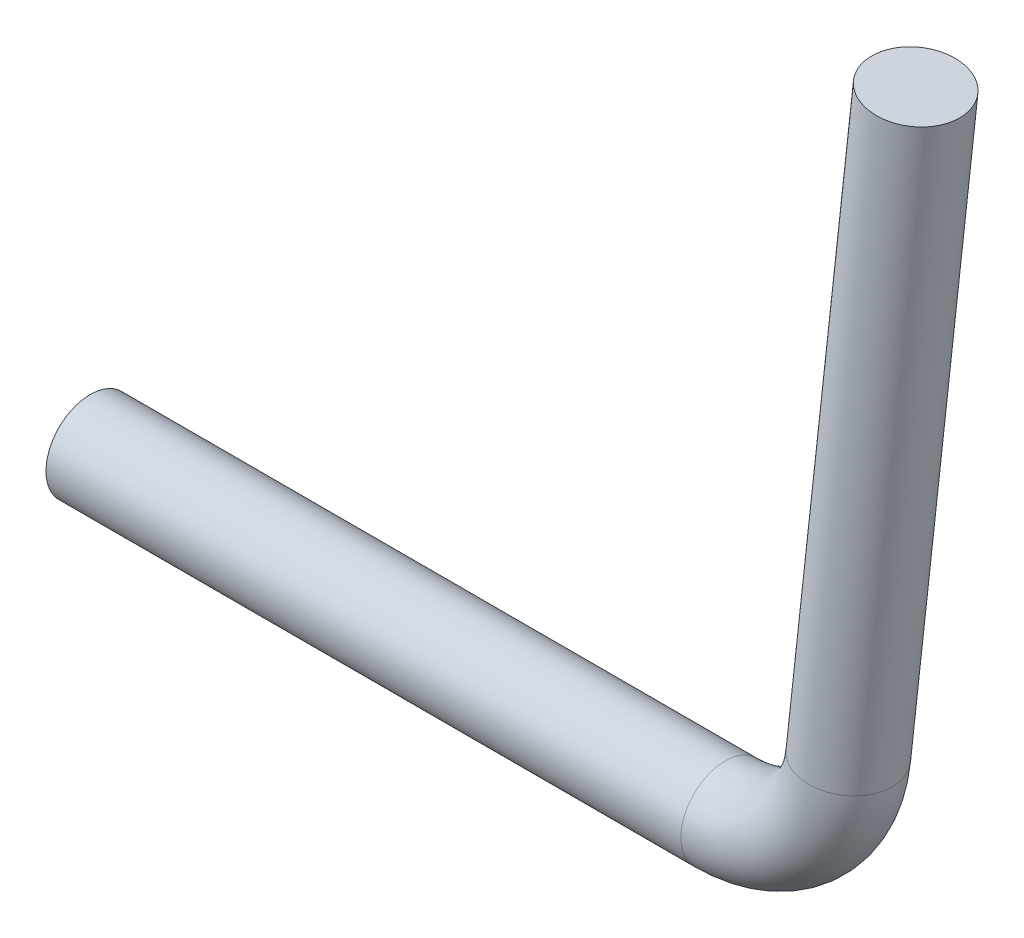
from build123d import *

# Parameters (mm, degrees)
SWEEP2_PROFILE_R = 2.5


with BuildPart() as part:
    # Sweep2: sweep along a path in Sketch1
    with BuildLine(Plane.XY) as sweep2_path:
        Line((-31.80803431, 9.611579787), (4.060509597, 9.611579787))
        ThreePointArc((4.060509597, 9.611579787), (8.73169863, 11.398136297), (11.018503897, 15.845867495))
        Line((11.018503897, 15.845867495), (14.829920229, 50.48004199))
    # Sweep2 profile (on start of the path) → Sweep2 (sweep)
    with BuildSketch(Plane(origin=(-31.80803431, 9.611579787, 0), x_dir=(0, 0, 1), z_dir=(1, 0, 0))):
        Circle(SWEEP2_PROFILE_R)
    sweep(path=sweep2_path.line)


solid = part.part
